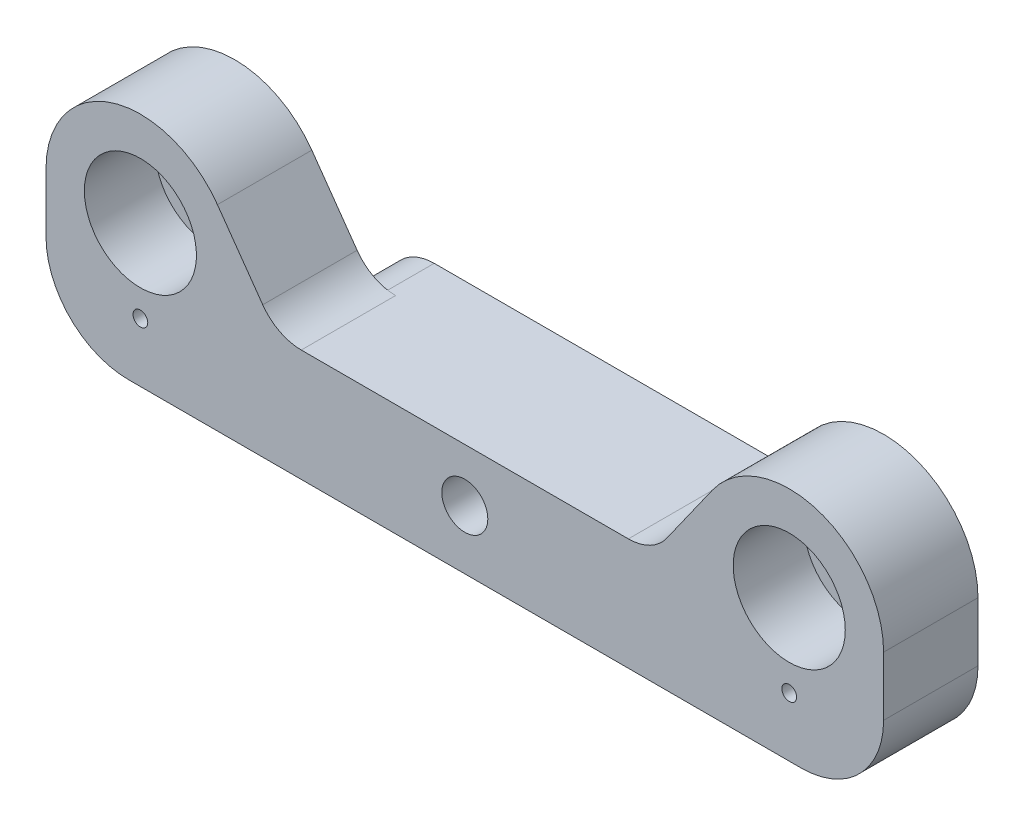
from build123d import *

# Parameters (mm, degrees)
SKETCH1_W                     = 68.5
SKETCH1_H                     = 7
BOSS_EXTRUDE1_DEPTH           = 12
BOSS_EXTRUDE1_DEPTH_BACK      = 12
SKETCH2_W                     = 15.5
SKETCH2_H                     = 6.3
CUT_EXTRUDE1_DEPTH            = 8
SKETCH3_W                     = 13.5
SKETCH3_H                     = 8.85
BOSS_EXTRUDE2_DEPTH           = 10
SKETCH4_R                     = 3.1
CUT_EXTRUDE2_DEPTH            = 22
CUT_EXTRUDE2_DEPTH_BACK       = 24.5
CUT_EXTRUDE3_DEPTH            = 5
SKETCH6_R                     = 6.2
CUT_EXTRUDE4_DEPTH            = 1
MIRROR2_COPY_1_SKETCH_R       = 6.2
MIRROR2_COPY_1_DEPTH          = 1
SKETCH7_W                     = 13.5
SKETCH7_H                     = 8.5
CUT_EXTRUDE5_DEPTH            = 1
MIRROR5_COPY_1_SKETCH_W       = 13.5
MIRROR5_COPY_1_SKETCH_H       = 8.5
MIRROR5_COPY_1_DEPTH          = 1
TAP_DRILL_FOR_M2_TAP1_D       = 1.6
CUT_EXTRUDE6_DEPTH            = 27
SKETCH12_W                    = 73.606041854
SKETCH12_H                    = 30.436261762
CUT_EXTRUDE7_DEPTH            = 22
F_2_0_2_DIAMETER_HOLE2_D      = 2
F_2_0_2_DIAMETER_HOLE2_DEPTH  = 16
F_2_0_2_DIAMETER_HOLE2_TIP    = 0.600860619
F_2_0_2_DIAMETER_HOLE1_D      = 2
F_2_0_2_DIAMETER_HOLE1_DEPTH  = 16
F_2_0_2_DIAMETER_HOLE1_TIP    = 0.600860619
ESQUISSE5_R                   = 3.1
BOSS_EXTRU_1_DEPTH            = 1
ESQUISSE6_R                   = 4.75
ENL_V_MAT_EXTRU_1_DEPTH       = 6
ESQUISSE7_R                   = 0.8
BOSS_EXTRU_2_DEPTH            = 8.85
ESQUISSE9_R                   = 0.6
ENL_V_MAT_EXTRU_2_DEPTH       = 13
BOSS_EXTRUDE3_DEPTH           = 1.5
SKETCH24_W                    = 17.102440496
SKETCH24_H                    = 20.071516443
CUT_EXTRUDE8_DEPTH            = 0.85
BOSS_EXTRUDE4_DEPTH           = 8
M2_5_CLEARANCE_HOLE1_D        = 2.9
M2_5_CLEARANCE_HOLE1_DEPTH    = 24
M2_5_CLEARANCE_HOLE1_TIP      = 0.871247898
SKETCH26_W                    = 37.5
SKETCH26_H                    = 12
BOSS_EXTRUDE6_DEPTH           = 1
SKETCH27_R                    = 1.95
CUT_EXTRUDE9_DEPTH            = 4.5
CHAMFER2_SIZE                 = 2.5
SKETCH28_R                    = 1
BOSS_EXTRUDE7_DEPTH           = 2
SKETCH29_R                    = 8
SKETCH29_R_2                  = 4.75
BOSS_EXTRUDE8_DEPTH           = 8
SKETCH31_W                    = 1.25
SKETCH31_H                    = 12
BOSS_EXTRUDE9_DEPTH           = 8
FILLET1_R                     = 7
BOSS_EXTRUDE10_DEPTH          = 8
FILLET2_R                     = 4
TAP_DRILL_FOR_M1_6_TAP1_D     = 1.25
TAP_DRILL_FOR_M1_6_TAP1_DEPTH = 30.5
CHAMFER3_SIZE                 = 3.5
FILLET3_R                     = 4


with BuildPart() as part:
    # Sketch1 → Boss-Extrude1 (new body, two sides)
    with BuildSketch(Plane.XY) as boss_extrude1_sk:
        Rectangle(SKETCH1_W, SKETCH1_H)
    extrude(amount=BOSS_EXTRUDE1_DEPTH)
    extrude(boss_extrude1_sk.sketch, amount=-BOSS_EXTRUDE1_DEPTH_BACK)

    # Sketch2 → Cut-Extrude1 (cut, through all)
    with BuildSketch(Plane(origin=(0, 3.5, 0), x_dir=(1, 0, 0), z_dir=(0, 1, 0))):
        with Locations((-26.5, 0)):
            Rectangle(SKETCH2_W, SKETCH2_H)
        with Locations((26.5, 0)):
            Rectangle(SKETCH2_W, SKETCH2_H)
    extrude(amount=-CUT_EXTRUDE1_DEPTH, mode=Mode.SUBTRACT)

    # Sketch3 → Boss-Extrude2 (add)
    with BuildSketch(Plane(origin=(0, 3.5, 0), x_dir=(1, 0, 0), z_dir=(0, 1, 0))):
        with Locations((-27.5, 7.575)):
            Rectangle(SKETCH3_W, SKETCH3_H)
        with Locations((-27.5, -7.575)):
            Rectangle(SKETCH3_W, SKETCH3_H)
        with Locations((27.5, -7.575)):
            Rectangle(SKETCH3_W, SKETCH3_H)
        with Locations((27.5, 7.575)):
            Rectangle(SKETCH3_W, SKETCH3_H)
    extrude(amount=BOSS_EXTRUDE2_DEPTH)

    # Sketch4 → Cut-Extrude2 (cut, two sides)
    with BuildSketch(Plane.XY) as cut_extrude2_sk:
        with Locations((-27.5, 7)):
            Circle(SKETCH4_R)
        with Locations((27.5, 7)):
            Circle(SKETCH4_R)
    extrude(amount=CUT_EXTRUDE2_DEPTH, mode=Mode.SUBTRACT)
    extrude(cut_extrude2_sk.sketch, amount=-CUT_EXTRUDE2_DEPTH_BACK, mode=Mode.SUBTRACT)

    # Sketch5 → Cut-Extrude3 (cut)
    with BuildSketch(Plane.XY):
        Polygon((15, 3.5), (36.256888292, -2.195766051), (36.256888292, 13.5), (15, 13.5), align=None)
    extrude(amount=-CUT_EXTRUDE3_DEPTH, mode=Mode.SUBTRACT)

    # Sketch6 → Cut-Extrude4 (cut)
    with BuildSketch(Plane.XY.offset(12)):
        with Locations((27.5, 7)):
            Circle(SKETCH6_R)
    cut_extrude4 = extrude(amount=-CUT_EXTRUDE4_DEPTH, mode=Mode.SUBTRACT)

    # Mirror1: Cut-Extrude4 across plane
    add(cut_extrude4.mirror(Plane.XY), mode=Mode.SUBTRACT)

    # Mirror2: Cut-Extrude4 across plane
    add(cut_extrude4.mirror(Plane(origin=(0, 0, 0), x_dir=(0, 0, 1), z_dir=(1, 0, 0))), mode=Mode.SUBTRACT)

    # Mirror2 copy 1 sketch → Mirror2 copy 1 (cut)
    with BuildSketch(Plane(origin=(0, 0, -12), x_dir=(-1, 0, 0), z_dir=(0, 0, -1))):
        with Locations((27.5, 7)):
            Circle(MIRROR2_COPY_1_SKETCH_R)
    extrude(amount=-MIRROR2_COPY_1_DEPTH, mode=Mode.SUBTRACT)

    # Sketch7 → Cut-Extrude5 (cut)
    with BuildSketch(Plane.XY.offset(12)):
        with Locations((-27.5, 9.25)):
            Rectangle(SKETCH7_W, SKETCH7_H)
    cut_extrude5 = extrude(amount=-CUT_EXTRUDE5_DEPTH, mode=Mode.SUBTRACT)

    # Mirror3: Cut-Extrude5 across plane
    add(cut_extrude5.mirror(Plane(origin=(0, 0, 0), x_dir=(0, 0, 1), z_dir=(1, 0, 0))), mode=Mode.SUBTRACT)

    # Mirror5: Cut-Extrude5 across plane
    add(cut_extrude5.mirror(Plane.XY), mode=Mode.SUBTRACT)

    # Mirror5 copy 1 sketch → Mirror5 copy 1 (cut)
    with BuildSketch(Plane(origin=(0, 0, -12), x_dir=(-1, 0, 0), z_dir=(0, 0, -1))):
        with Locations((-27.5, 9.25)):
            Rectangle(MIRROR5_COPY_1_SKETCH_W, MIRROR5_COPY_1_SKETCH_H)
    extrude(amount=-MIRROR5_COPY_1_DEPTH, mode=Mode.SUBTRACT)

    # Tap Drill for M2 Tap1 (through all)
    with Locations(Plane.XY.offset(12)):
        with Locations((-25, 0), (0, 0), (25, 0)):
            Hole(TAP_DRILL_FOR_M2_TAP1_D / 2)

    # Sketch11 → Cut-Extrude6 (cut)
    with BuildSketch(Plane.XY.offset(12)):
        with BuildLine():
            Line((-34.25, 7), (-34.25, 21.221242017))
            Line((-34.25, 21.221242017), (-20.75, 21.221242017))
            Line((-20.75, 21.221242017), (-20.75, 7))
            ThreePointArc((-20.75, 7), (-27.5, 13.75), (-34.25, 7))
        make_face()
    cut_extrude6 = extrude(amount=-CUT_EXTRUDE6_DEPTH, mode=Mode.SUBTRACT)

    # Mirror6: Cut-Extrude6 across plane
    add(cut_extrude6.mirror(Plane(origin=(0, 0, 0), x_dir=(0, 0, 1), z_dir=(1, 0, 0))), mode=Mode.SUBTRACT)

    # Sketch12 → Cut-Extrude7 (cut)
    with BuildSketch(Plane.XY):
        Rectangle(SKETCH12_W, SKETCH12_H)
    extrude(amount=-CUT_EXTRUDE7_DEPTH, mode=Mode.SUBTRACT)

    # 2.0 _2_ Diameter Hole2
    with Locations(Plane.XY.offset(12)):
        with Locations((-15, 0)):
            Hole(F_2_0_2_DIAMETER_HOLE2_D / 2, depth=F_2_0_2_DIAMETER_HOLE2_DEPTH)
            with Locations((0, 0, -(F_2_0_2_DIAMETER_HOLE2_DEPTH + F_2_0_2_DIAMETER_HOLE2_TIP / 2))):  # 118° drill point
                Cone(0, F_2_0_2_DIAMETER_HOLE2_D / 2, F_2_0_2_DIAMETER_HOLE2_TIP, mode=Mode.SUBTRACT)

    # 2.0 _2_ Diameter Hole1
    with Locations(Plane.XY.offset(12)):
        with Locations((15, 0)):
            Hole(F_2_0_2_DIAMETER_HOLE1_D / 2, depth=F_2_0_2_DIAMETER_HOLE1_DEPTH)
            with Locations((0, 0, -(F_2_0_2_DIAMETER_HOLE1_DEPTH + F_2_0_2_DIAMETER_HOLE1_TIP / 2))):  # 118° drill point
                Cone(0, F_2_0_2_DIAMETER_HOLE1_D / 2, F_2_0_2_DIAMETER_HOLE1_TIP, mode=Mode.SUBTRACT)

    # Esquisse5 → Boss.-Extru.1 (add)
    with BuildSketch(Plane.XY.offset(11)):
        with BuildLine():
            Line((20.75, 5), (21.6314397, 5))
            ThreePointArc((21.6314397, 5), (27.5, 0.8), (33.3685603, 5))
            Line((33.3685603, 5), (34.25, 5))
            Line((34.25, 5), (34.25, 7))
            ThreePointArc((34.25, 7), (32.878089133, 11.079051027), (29.320027472, 13.5))
            Line((29.320027472, 13.5), (25.679972528, 13.5))
            ThreePointArc((25.679972528, 13.5), (22.121910867, 11.079051027), (20.75, 7))
            Line((20.75, 7), (20.75, 5))
        make_face()
        with Locations((27.5, 7)):
            Circle(ESQUISSE5_R, mode=Mode.SUBTRACT)
    boss_extru_1 = extrude(amount=BOSS_EXTRU_1_DEPTH)

    # Esquisse6 → Enl_v. mat.-Extru.1 (cut)
    with BuildSketch(Plane.XY.offset(12)):
        with Locations((27.5, 7)):
            Circle(ESQUISSE6_R)
    enl_v_mat_extru_1 = extrude(amount=-ENL_V_MAT_EXTRU_1_DEPTH, mode=Mode.SUBTRACT)

    # Sym_trie1: Boss.-Extru.1, Enl_v. mat.-Extru.1 across plane
    add(boss_extru_1.mirror(Plane(origin=(0, 0, 0), x_dir=(0, 0, 1), z_dir=(1, 0, 0))))
    add(enl_v_mat_extru_1.mirror(Plane(origin=(0, 0, 0), x_dir=(0, 0, 1), z_dir=(1, 0, 0))), mode=Mode.SUBTRACT)

    # Esquisse7 → Boss.-Extru.2 (add)
    with BuildSketch(Plane.XY.offset(12)):
        with Locations((-25, 0)):
            Circle(ESQUISSE7_R)
        with Locations((25, 0)):
            Circle(ESQUISSE7_R)
    extrude(amount=-BOSS_EXTRU_2_DEPTH)

    # Esquisse9 → Enl_v. mat.-Extru.2 (cut, through all)
    with BuildSketch(Plane.XY.offset(12)):
        with Locations((27.5, 0)):
            Circle(ESQUISSE9_R)
        with Locations((-27.5, 0)):
            Circle(ESQUISSE9_R)
    extrude(amount=-ENL_V_MAT_EXTRU_2_DEPTH, mode=Mode.SUBTRACT)

    # Sketch18 → Boss-Extrude3 (add)
    with BuildSketch(Plane.XZ.offset(3.5)):
        Polygon((-18.75, 0), (18.75, 0), (18.75, 3.15), (34.25, 3.15), (34.25, 12), (-34.25, 12), (-34.25, 3.15), (-18.75, 3.15), align=None)
    extrude(amount=BOSS_EXTRUDE3_DEPTH)

    # Sketch24 → Cut-Extrude8 (cut)
    with BuildSketch(Plane(origin=(0, 0, 3.15), x_dir=(-1, 0, 0), z_dir=(0, 0, -1))):
        with Locations((-27.301220248, 5.035758222)):
            Rectangle(SKETCH24_W, SKETCH24_H)
        with Locations((27.301220248, 5.035758222)):
            Rectangle(SKETCH24_W, SKETCH24_H)
    extrude(amount=-CUT_EXTRUDE8_DEPTH, mode=Mode.SUBTRACT)

    # Sketch19 → Boss-Extrude4 (add)
    with BuildSketch(Plane(origin=(0, 0, 4), x_dir=(-1, 0, 0), z_dir=(0, 0, -1))):
        Polygon((22.565408914, 11.605682449), (15, 3.5), (20.75, 3.5), align=None)
        Polygon((-20.75, 3.5), (-15, 3.5), (-22.565408914, 11.605682449), align=None)
    extrude(amount=-BOSS_EXTRUDE4_DEPTH)

    # M2.5 Clearance Hole1
    with Locations(Plane.XY.offset(12)):
        with Locations((0, 0)):
            Hole(M2_5_CLEARANCE_HOLE1_D / 2, depth=M2_5_CLEARANCE_HOLE1_DEPTH)
            with Locations((0, 0, -(M2_5_CLEARANCE_HOLE1_DEPTH + M2_5_CLEARANCE_HOLE1_TIP / 2))):  # 118° drill point
                Cone(0, M2_5_CLEARANCE_HOLE1_D / 2, M2_5_CLEARANCE_HOLE1_TIP, mode=Mode.SUBTRACT)

    # Sketch26 → Boss-Extrude6 (add)
    with BuildSketch(Plane(origin=(0, 3.5, 0), x_dir=(1, 0, 0), z_dir=(0, 1, 0))):
        with Locations((0, -6)):
            Rectangle(SKETCH26_W, SKETCH26_H)
    extrude(amount=BOSS_EXTRUDE6_DEPTH)

    # Sketch27 → Cut-Extrude9 (cut)
    with BuildSketch(Plane.XY.offset(12)):
        Circle(SKETCH27_R)
    extrude(amount=-CUT_EXTRUDE9_DEPTH, mode=Mode.SUBTRACT)

    # Chamfer2
    chamfer2_edges = [part.edges().sort_by_distance(p)[0] for p in [
        (-18.75, 4.5, 2),
        (18.75, 4.5, 2),
    ]]
    chamfer(chamfer2_edges, length=CHAMFER2_SIZE)

    # Sketch28 → Boss-Extrude7 (add)
    with BuildSketch(Plane.XY.offset(12)):
        with Locations((-15, 0)):
            Circle(SKETCH28_R)
        with Locations((15, 0)):
            Circle(SKETCH28_R)
    extrude(amount=-BOSS_EXTRUDE7_DEPTH)

    # Sketch29 → Boss-Extrude8 (add)
    with BuildSketch(Plane(origin=(0, 0, 4), x_dir=(-1, 0, 0), z_dir=(0, 0, -1))):
        with Locations((27.5, 7)):
            Circle(SKETCH29_R)
        with Locations((27.5, 7)):
            Circle(SKETCH29_R_2, mode=Mode.SUBTRACT)
        with Locations((-27.5, 7)):
            Circle(SKETCH29_R)
        with Locations((-27.5, 7)):
            Circle(SKETCH29_R_2, mode=Mode.SUBTRACT)
    extrude(amount=-BOSS_EXTRUDE8_DEPTH)

    # Sketch31 → Boss-Extrude9 (add)
    with BuildSketch(Plane.XY.offset(12)):
        with Locations((-34.875, 1)):
            Rectangle(SKETCH31_W, SKETCH31_H)
        with Locations((34.875, 1)):
            Rectangle(SKETCH31_W, SKETCH31_H)
    extrude(amount=-BOSS_EXTRUDE9_DEPTH)

    # Fillet1
    fillet1_edges = [part.edges().sort_by_distance(p)[0] for p in [
        (-35.5, -5, 8),
        (35.5, -5, 8),
    ]]
    fillet(fillet1_edges, radius=FILLET1_R)

    # Sketch32 → Boss-Extrude10 (add)
    with BuildSketch(Plane(origin=(0, 0, 4), x_dir=(-1, 0, 0), z_dir=(0, 0, -1))):
        Polygon((-15.933346324, 4.5), (-20.968428631, 11.619369595), (-19.635586921, 8.466631145), align=None)
        Polygon((19.635586921, 8.466631145), (15.933346324, 4.5), (20.968428631, 11.619369595), align=None)
    extrude(amount=-BOSS_EXTRUDE10_DEPTH)

    # Fillet2
    fillet2_edges = [part.edges().sort_by_distance(p)[0] for p in [
        (15.933346324, 4.5, 8),
        (-15.933346324, 4.5, 8),
    ]]
    fillet(fillet2_edges, radius=FILLET2_R)

    # Tap Drill for M1.6 Tap1
    with Locations(Plane.XY.offset(12)):
        with Locations((-27.500000011, -0.006912425), (27.499997471, 0.006912424)):
            Hole(TAP_DRILL_FOR_M1_6_TAP1_D / 2, depth=TAP_DRILL_FOR_M1_6_TAP1_DEPTH)

    # Chamfer3
    chamfer3_edges = [part.edges().sort_by_distance(p)[0] for p in [
        (-18.75, -5, 2),
        (18.75, -5, 2),
    ]]
    chamfer(chamfer3_edges, length=CHAMFER3_SIZE)

    # Fillet3
    fillet3_edges = [part.edges().sort_by_distance(p)[0] for p in [
        (-16.25, 4.5, 2),
        (16.25, 4.5, 2),
        (18.75, 2, 2),
        (-18.75, 2, 2),
        (15.25, -5, 2),
        (-15.25, -5, 2),
        (-18.75, -1.5, 2),
        (18.75, -1.5, 2),
    ]]
    fillet(fillet3_edges, radius=FILLET3_R)


solid = part.part
